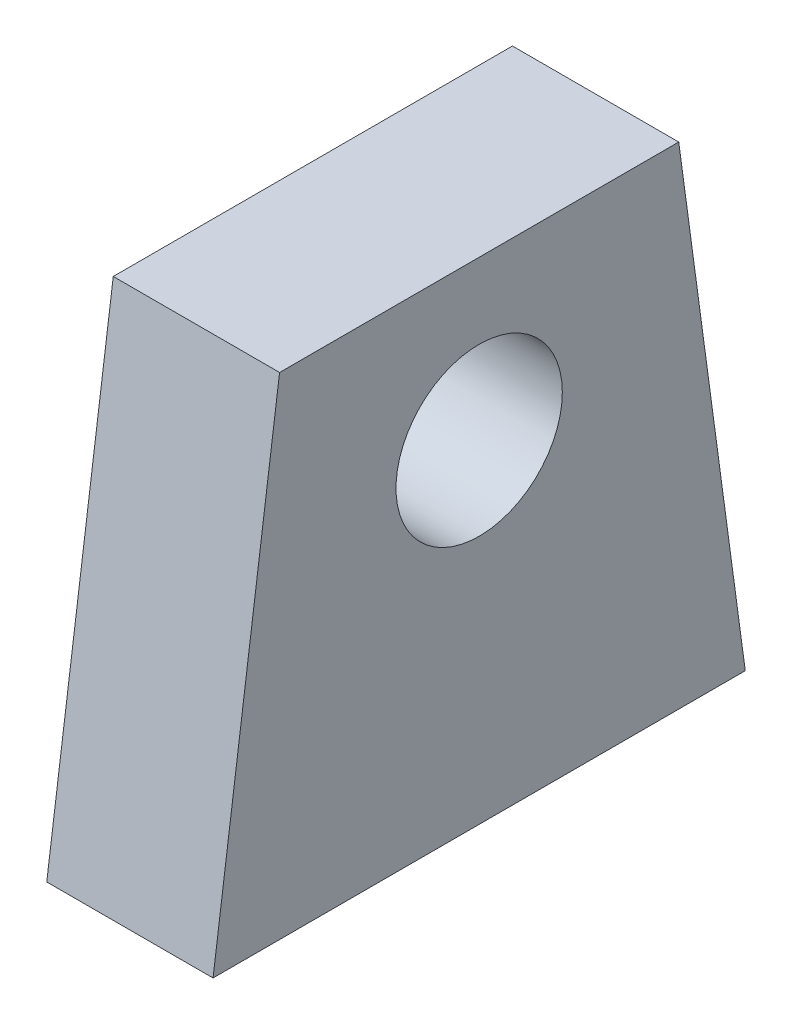
from build123d import *

# Parameters (mm, degrees)
SKETCH1_R           = 2.5
BOSS_EXTRUDE1_DEPTH = 5


with BuildPart() as part:
    # Sketch1 → Boss-Extrude1 (new body)
    with BuildSketch(Plane(origin=(0, 0, 0), x_dir=(0, 0, -1), z_dir=(1, 0, 0))):
        Polygon((8, -10), (-8, -10), (-6, 4.765251939), (6, 4.765251939), align=None)
        Circle(SKETCH1_R, mode=Mode.SUBTRACT)
    extrude(amount=BOSS_EXTRUDE1_DEPTH)


solid = part.part
